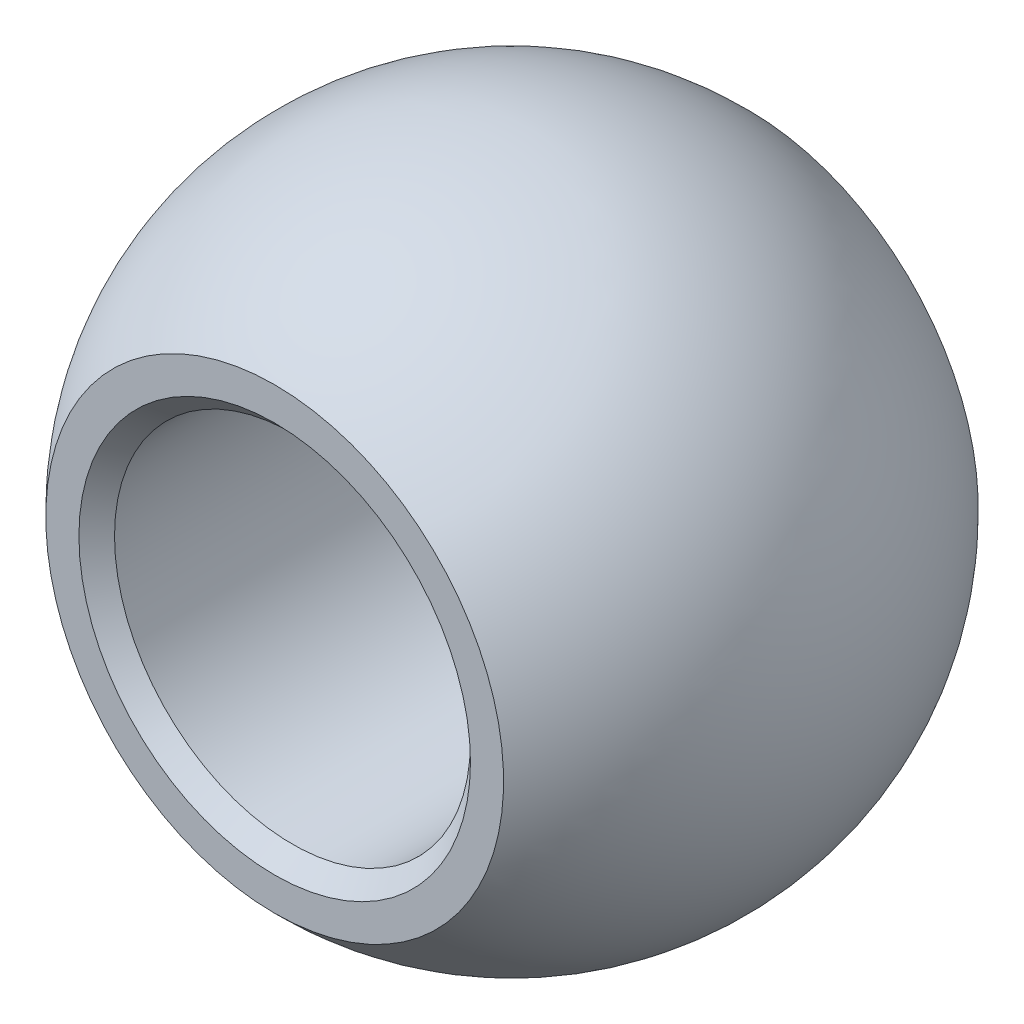
from build123d import *

# Parameters (mm, degrees)
CUT_EXTRUDE3_DEPTH      = 20.251744726
CUT_EXTRUDE3_DEPTH_BACK = 20.251744726
SKETCH8_W               = 6.85015111
SKETCH8_H               = 35.814207494
CUT_EXTRUDE4_DEPTH      = 20.251744726
CUT_EXTRUDE4_DEPTH_BACK = 20.251744726
SKETCH10_R              = 6
CHAMFER1_SIZE           = 0.6


with BuildPart() as part:
    # Sketch7 → Revolve3 (revolve)
    with BuildSketch(Plane.XY):
        with BuildLine():
            Line((0, 11.115), (0, -11.115))
            ThreePointArc((0, -11.115), (11.115, 0), (0, 11.115))
        make_face()
    revolve(axis=Axis((0, 0, 0), (0, -1, 0)))

    # Sketch8 → Cut-Extrude3 (cut, two sides: drawn at the far end of the back side and taken through both)
    with BuildSketch(Plane(origin=(0, 0, 0), x_dir=(0, 0, -1), z_dir=(1, 0, 0)).offset(-CUT_EXTRUDE3_DEPTH_BACK)):
        with Locations((-11.425075555, 0)):
            Rectangle(SKETCH8_W, SKETCH8_H)
        with Locations((11.425075555, 0)):
            Rectangle(SKETCH8_W, SKETCH8_H)
    extrude(amount=CUT_EXTRUDE3_DEPTH + CUT_EXTRUDE3_DEPTH_BACK, mode=Mode.SUBTRACT)

    # Sketch10 → Cut-Extrude4 (cut, two sides: drawn at the far end of the back side and taken through both)
    with BuildSketch(Plane.XY.offset(-CUT_EXTRUDE4_DEPTH_BACK)):
        Circle(SKETCH10_R)
    extrude(amount=CUT_EXTRUDE4_DEPTH + CUT_EXTRUDE4_DEPTH_BACK, mode=Mode.SUBTRACT)

    # Chamfer1
    chamfer1_edges = [part.edges().sort_by_distance(p)[0] for p in [
        (-6, 0, -8),
        (-6, 0, 8),
    ]]
    chamfer(chamfer1_edges, length=CHAMFER1_SIZE)


solid = part.part
